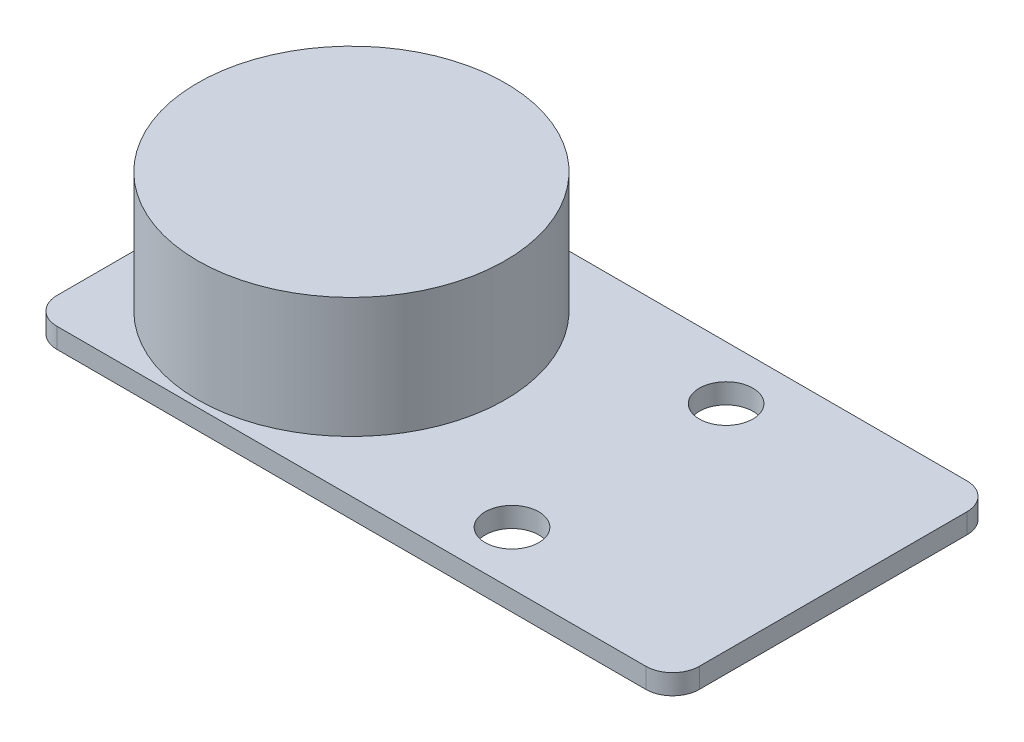
from build123d import *

# Parameters (mm, degrees)
SKETCH_1_W          = 48
SKETCH_1_H          = 24
EXTRUDE_1_DEPTH     = 1.5
FILLET_1_R          = 2
CUT_EXTRUDE_1_REACH = 3.5
SKETCH_2_R          = 2
SKETCH_3_R          = 11.5
EXTRUDE_2_DEPTH     = 9


with BuildPart() as part:
    # 草图1 → 凸台-拉伸1 (new body)
    with BuildSketch(Plane(origin=(0, 0, 0), x_dir=(1, 0, 0), z_dir=(0, 1, 0))):
        Rectangle(SKETCH_1_W, SKETCH_1_H)
    extrude(amount=EXTRUDE_1_DEPTH)

    # 圆角1
    fillet_1_edges = [part.edges().sort_by_distance(p)[0] for p in [
        (-24, 0.75, -12),
        (24, 0.75, -12),
        (24, 0.75, 12),
        (-24, 0.75, 12),
    ]]
    fillet(fillet_1_edges, radius=FILLET_1_R)

    # 草图2 → 切除-拉伸1 (cut, up to next)
    with BuildSketch(Plane(origin=(0, 1.5, 0), x_dir=(1, 0, 0), z_dir=(0, 1, 0)), mode=Mode.PRIVATE) as cut_extrude_1_sk1:
        with Locations((8, 8)):
            Circle(SKETCH_2_R)
    cut_extrude_1_tool1 = extrude(cut_extrude_1_sk1.sketch, amount=-CUT_EXTRUDE_1_REACH, mode=Mode.PRIVATE) & part.part
    add(cut_extrude_1_tool1.solids().sort_by_distance((8, 1.5, -8))[0], mode=Mode.SUBTRACT)
    # 草图2 → 切除-拉伸1 (cut, up to next)
    with BuildSketch(Plane(origin=(0, 1.5, 0), x_dir=(1, 0, 0), z_dir=(0, 1, 0)), mode=Mode.PRIVATE) as cut_extrude_1_sk2:
        with Locations((8, -8)):
            Circle(SKETCH_2_R)
    cut_extrude_1_tool2 = extrude(cut_extrude_1_sk2.sketch, amount=-CUT_EXTRUDE_1_REACH, mode=Mode.PRIVATE) & part.part
    add(cut_extrude_1_tool2.solids().sort_by_distance((8, 1.5, 8))[0], mode=Mode.SUBTRACT)

    # 草图3 → 凸台-拉伸2 (add)
    with BuildSketch(Plane(origin=(0, 1.5, 0), x_dir=(1, 0, 0), z_dir=(0, 1, 0))):
        with Locations((-12, 0)):
            Circle(SKETCH_3_R)
    extrude(amount=EXTRUDE_2_DEPTH)


solid = part.part
